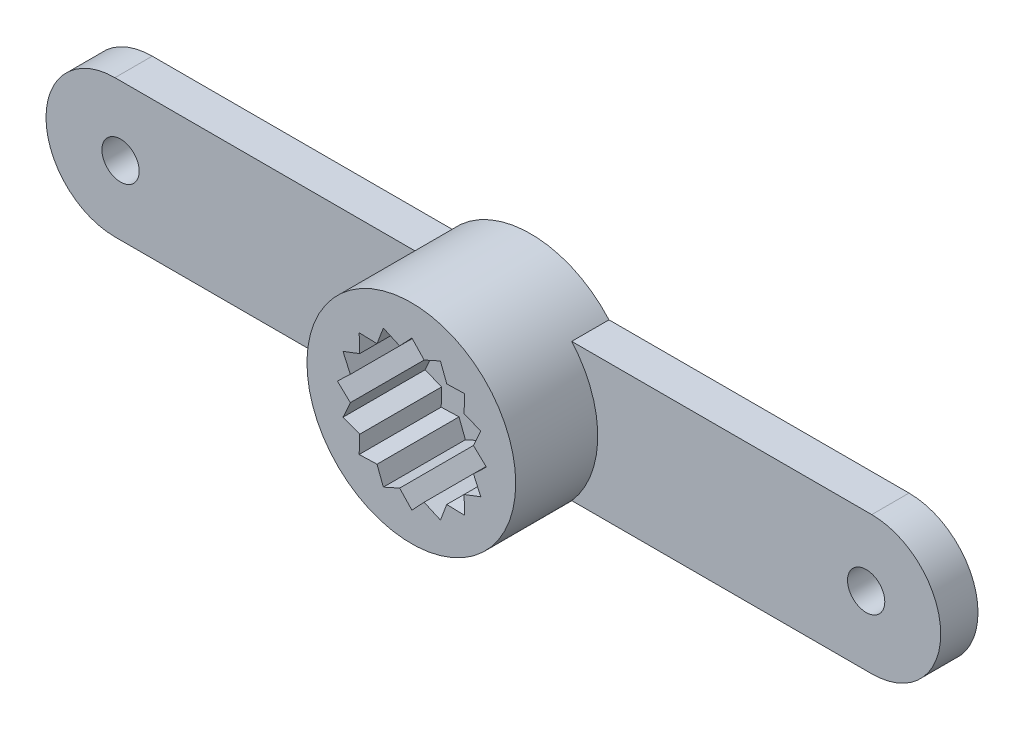
from build123d import *

# Parameters (mm, degrees)
SKETCH1_R           = 2.8
BOSS_EXTRUDE1_DEPTH = 3.2
CUT_EXTRUDE1_DEPTH  = 2.2
SKETCH3_R           = 0.75
CUT_EXTRUDE2_DEPTH  = 1
BOSS_EXTRUDE2_DEPTH = 1
CUT_EXTRUDE3_REACH  = 5.2
SKETCH5_R           = 0.5


with BuildPart() as part:
    # Sketch1 → Boss-Extrude1 (new body)
    with BuildSketch(Plane.XY):
        Circle(SKETCH1_R)
    extrude(amount=BOSS_EXTRUDE1_DEPTH)

    # Sketch2 → Cut-Extrude1 (cut)
    with BuildSketch(Plane.XY.offset(3.2)):
        Polygon((0.014651949, 1.985348051), (-0.313876209, 1.636970634), (-0.750714916, 1.833107116), (-0.920917091, 1.385526068), (-1.399561614, 1.399561614), (-1.385526068, 0.920917091), (-1.833107116, 0.750714916), (-1.636970634, 0.313876209), (-1.985348051, -0.014651949), (-1.636970634, -0.343180107), (-1.833107116, -0.780018813), (-1.385526068, -0.950220989), (-1.399561614, -1.428865511), (-0.920917091, -1.414829965), (-0.750714916, -1.862411014), (-0.313876209, -1.666274532), (0.014651949, -2.014651949), (0.343180107, -1.666274532), (0.780018813, -1.862411014), (0.950220989, -1.414829965), (1.428865511, -1.428865511), (1.414829965, -0.950220989), (1.862411014, -0.780018813), (1.666274532, -0.343180107), (2.014651949, -0.014651949), (1.666274532, 0.313876209), (1.862411014, 0.750714916), (1.414829965, 0.920917091), (1.428865511, 1.399561614), (0.950220989, 1.385526068), (0.780018813, 1.833107116), (0.343180107, 1.636970634), align=None)
    extrude(amount=-CUT_EXTRUDE1_DEPTH, mode=Mode.SUBTRACT)

    # Sketch3 → Cut-Extrude2 (cut)
    with BuildSketch(Plane.XY):
        Circle(SKETCH3_R)
    extrude(amount=CUT_EXTRUDE2_DEPTH, mode=Mode.SUBTRACT)

    # Sketch4 → Boss-Extrude2 (add)
    with BuildSketch(Plane.XY):
        with BuildLine():
            ThreePointArc((10.15, 1.85), (12, 0), (10.15, -1.85))
            Line((10.15, -1.85), (0.75, -1.85))
            Line((0.75, -1.85), (0.75, 1.85))
            Line((0.75, 1.85), (10.15, 1.85))
        make_face()
        with BuildLine():
            Line((-0.75, 1.85), (-10.15, 1.85))
            ThreePointArc((-10.15, 1.85), (-12, 0), (-10.15, -1.85))
            Line((-10.15, -1.85), (-0.75, -1.85))
            Line((-0.75, -1.85), (-0.75, 1.85))
        make_face()
    extrude(amount=BOSS_EXTRUDE2_DEPTH)

    # Sketch5 → Cut-Extrude3 (cut, up to next)
    with BuildSketch(Plane(origin=(0, 0, 0), x_dir=(-1, 0, 0), z_dir=(0, 0, -1)), mode=Mode.PRIVATE) as cut_extrude3_sk1:
        with Locations((10, 0)):
            Circle(SKETCH5_R)
    cut_extrude3_tool1 = extrude(cut_extrude3_sk1.sketch, amount=-CUT_EXTRUDE3_REACH, mode=Mode.PRIVATE) & part.part
    add(cut_extrude3_tool1.solids().sort_by_distance((-10, 0, 0))[0], mode=Mode.SUBTRACT)
    # Sketch5 → Cut-Extrude3 (cut, up to next)
    with BuildSketch(Plane(origin=(0, 0, 0), x_dir=(-1, 0, 0), z_dir=(0, 0, -1)), mode=Mode.PRIVATE) as cut_extrude3_sk2:
        with Locations((-10, 0)):
            Circle(SKETCH5_R)
    cut_extrude3_tool2 = extrude(cut_extrude3_sk2.sketch, amount=-CUT_EXTRUDE3_REACH, mode=Mode.PRIVATE) & part.part
    add(cut_extrude3_tool2.solids().sort_by_distance((10, 0, 0))[0], mode=Mode.SUBTRACT)


solid = part.part
